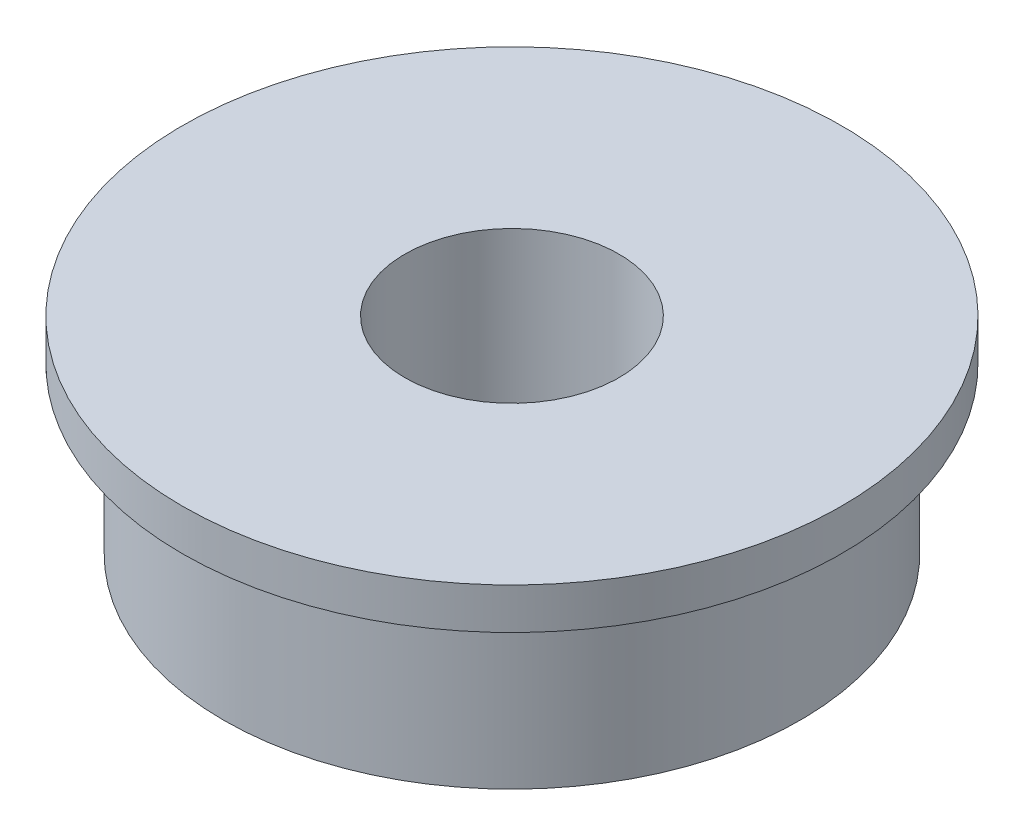
from build123d import *

# Parameters (mm, degrees)
SKETCH_1_R      = 7
SKETCH_1_R_2    = 2.6
EXTRUDE_1_DEPTH = 5
SKETCH_2_R      = 8
SKETCH_2_R_2    = 2.6
EXTRUDE_2_DEPTH = 1


with BuildPart() as part:
    # 草图1 → 凸台-拉伸1 (new body)
    with BuildSketch(Plane(origin=(0, 0, 0), x_dir=(1, 0, 0), z_dir=(0, 1, 0))):
        Circle(SKETCH_1_R)
        Circle(SKETCH_1_R_2, mode=Mode.SUBTRACT)
    extrude(amount=EXTRUDE_1_DEPTH)

    # 草图2 → 凸台-拉伸2 (add)
    with BuildSketch(Plane(origin=(0, 5, 0), x_dir=(1, 0, 0), z_dir=(0, 1, 0))):
        Circle(SKETCH_2_R)
        Circle(SKETCH_2_R_2, mode=Mode.SUBTRACT)
    extrude(amount=-EXTRUDE_2_DEPTH)


solid = part.part
